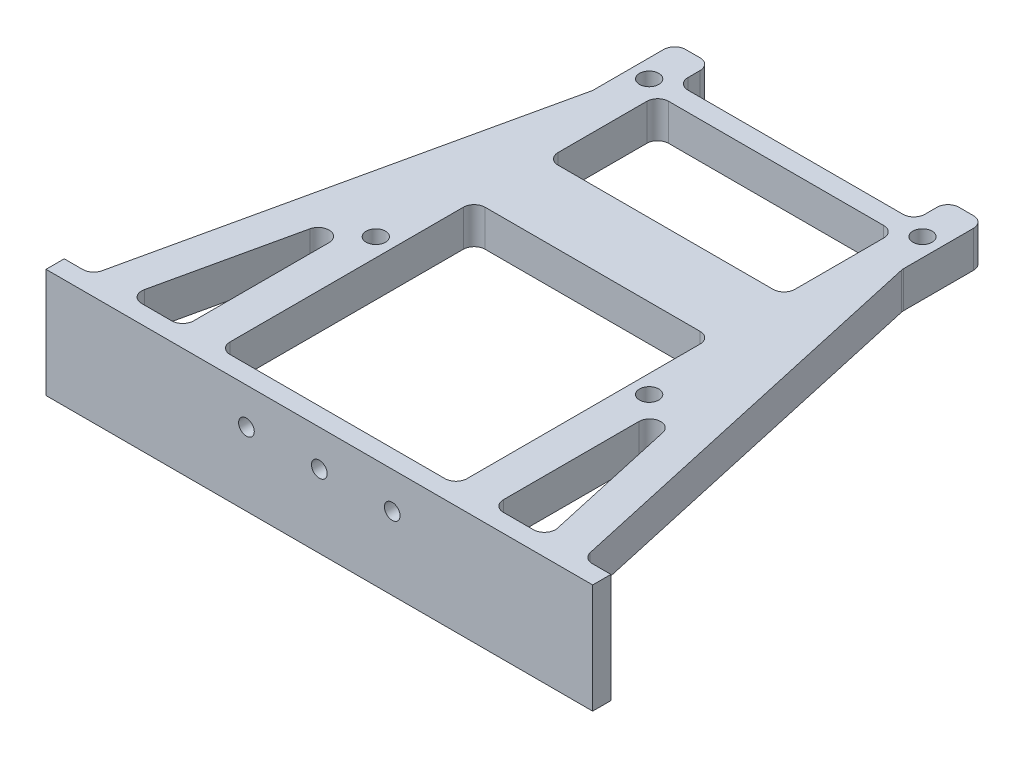
from build123d import *

# Parameters (mm, degrees)
SKETCH1_W           = 150
SKETCH1_H           = 30
BOSS_EXTRUDE1_DEPTH = 5
SKETCH2_R           = 2.15
CUT_EXTRUDE1_DEPTH  = 6
SKETCH3_W           = 10
SKETCH3_H           = 135
BOSS_EXTRUDE2_DEPTH = 10
BOSS_EXTRUDE3_DEPTH = 10
SKETCH6_W           = 20
SKETCH6_H           = 10
BOSS_EXTRUDE4_DEPTH = 65
SKETCH5_R           = 2.65
CUT_EXTRUDE3_DEPTH  = 10
BOSS_EXTRUDE5_REACH = 109.5
SKETCH7_W           = 5.3
SKETCH7_H           = 10
FILLET1_R           = 3
FILLET2_R           = 3


with BuildPart() as part:
    # Sketch1 → Boss-Extrude1 (new body)
    with BuildSketch(Plane.XY):
        with Locations((75, 15)):
            Rectangle(SKETCH1_W, SKETCH1_H)
    extrude(amount=BOSS_EXTRUDE1_DEPTH)

    # Sketch2 → Cut-Extrude1 (cut, through all)
    with BuildSketch(Plane.XY.offset(5)):
        with Locations((75, 20)):
            Circle(SKETCH2_R)
        with Locations((55, 20)):
            Circle(SKETCH2_R)
        with Locations((95, 20)):
            Circle(SKETCH2_R)
    extrude(amount=-CUT_EXTRUDE1_DEPTH, mode=Mode.SUBTRACT)

    # Sketch3 → Boss-Extrude2 (add)
    with BuildSketch(Plane(origin=(0, 30, 0), x_dir=(1, 0, 0), z_dir=(0, 1, 0))):
        with Locations((112.5, 67.5)):
            Rectangle(SKETCH3_W, SKETCH3_H)
        with Locations((37.5, 67.5)):
            Rectangle(SKETCH3_W, SKETCH3_H)
    extrude(amount=-BOSS_EXTRUDE2_DEPTH)

    # Sketch4 → Boss-Extrude3 (add)
    with BuildSketch(Plane(origin=(0, 30, 0), x_dir=(1, 0, 0), z_dir=(0, 1, 0))):
        Polygon((32.5, 67.5), (32.5, 112.5), (7.5, 0), (17.5, 0), align=None)
        Polygon((117.5, 112.5), (117.5, 67.5), (132.5, 0), (142.5, 0), align=None)
    extrude(amount=-BOSS_EXTRUDE3_DEPTH)

    # Sketch6 → Boss-Extrude4 (add)
    with BuildSketch(Plane.ZY.offset(-107.5)):
        with Locations((-80, 25)):
            Rectangle(SKETCH6_W, SKETCH6_H)
    extrude(amount=BOSS_EXTRUDE4_DEPTH)

    # Sketch5 → Cut-Extrude3 (cut)
    with BuildSketch(Plane(origin=(0, 30, 0), x_dir=(1, 0, 0), z_dir=(0, 1, 0))):
        with Locations((37.5, 48)):
            Circle(SKETCH5_R)
        with Locations((112.5, 48)):
            Circle(SKETCH5_R)
        with Locations((112.5, 123)):
            Circle(SKETCH5_R)
        with Locations((37.5, 123)):
            Circle(SKETCH5_R)
    extrude(amount=-CUT_EXTRUDE3_DEPTH, mode=Mode.SUBTRACT)

    # Sketch7 → Boss-Extrude5 (add, up to next)
    with BuildSketch(Plane.ZY.offset(-107.5), mode=Mode.PRIVATE) as boss_extrude5_sk1:
        with Locations((-123, 25)):
            Rectangle(SKETCH7_W, SKETCH7_H)
    boss_extrude5_tool1 = extrude(boss_extrude5_sk1.sketch, amount=BOSS_EXTRUDE5_REACH, mode=Mode.PRIVATE) - part.part
    add(boss_extrude5_tool1.solids().sort_by_distance((107.5, 25, -123))[0])

    # Fillet1
    fillet1_edges = [part.edges().sort_by_distance(p)[0] for p in [
        (42.5, 25, -125.65),
        (107.5, 25, -125.65),
        (32.5, 25, -135),
        (42.5, 25, -135),
        (42.5, 25, 0),
        (32.5, 25, 0),
        (117.5, 25, 0),
        (107.5, 25, 0),
        (107.5, 25, -135),
        (117.5, 25, -135),
        (32.5, 25, -67.5),
        (32.5, 25, -112.5),
        (7.5, 25, 0),
        (17.5, 25, 0),
        (117.5, 25, -112.5),
        (142.5, 25, 0),
        (132.5, 25, 0),
        (117.5, 25, -67.5),
        (42.5, 25, -70),
        (107.5, 25, -70),
    ]]
    fillet(fillet1_edges, radius=FILLET1_R)

    # Fillet2
    fillet2_edges = [part.edges().sort_by_distance(p)[0] for p in [
        (42.5, 25, -120.35),
        (107.5, 25, -120.35),
        (42.5, 25, -90),
        (107.5, 25, -90),
    ]]
    fillet(fillet2_edges, radius=FILLET2_R)


solid = part.part
